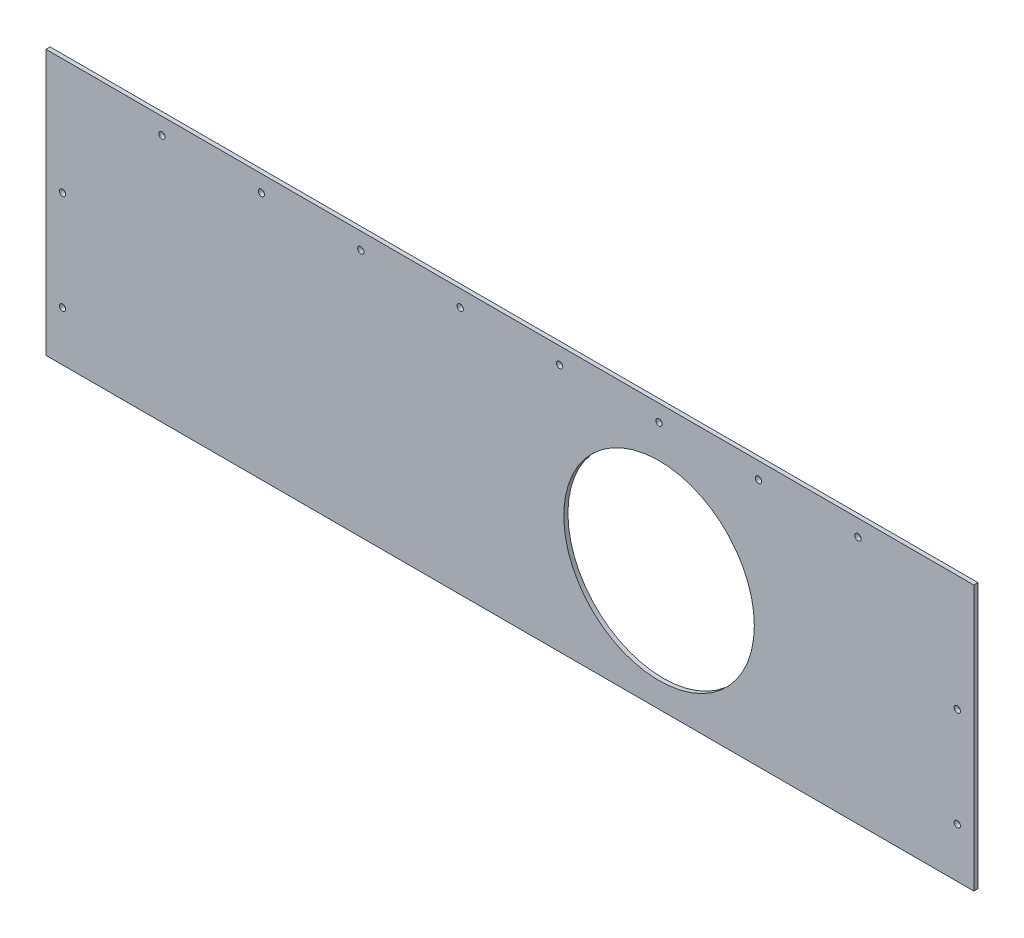
from build123d import *

# Parameters (mm, degrees)
SKETCH1_W           = 711.2
SKETCH1_H           = 203.2
BOSS_EXTRUDE1_DEPTH = 3.175
CUT_EXTRUDE1_REACH  = 5.175
SKETCH2_R           = 2.413
CUT_EXTRUDE2_REACH  = 5.175
SKETCH3_R           = 73.025


with BuildPart() as part:
    # Sketch1 → Boss-Extrude1 (new body)
    with BuildSketch(Plane.XY):
        with Locations((355.6, 101.6)):
            Rectangle(SKETCH1_W, SKETCH1_H)
    extrude(amount=BOSS_EXTRUDE1_DEPTH)

    # Sketch2 → Cut-Extrude1 (cut, up to next)
    with BuildSketch(Plane.XY.offset(3.175), mode=Mode.PRIVATE) as cut_extrude1_sk1:
        with Locations((12.7, 114.3)):
            Circle(SKETCH2_R)
    cut_extrude1_tool1 = extrude(cut_extrude1_sk1.sketch, amount=-CUT_EXTRUDE1_REACH, mode=Mode.PRIVATE) & part.part
    add(cut_extrude1_tool1.solids().sort_by_distance((12.7, 114.3, 3.175))[0], mode=Mode.SUBTRACT)
    # Sketch2 → Cut-Extrude1 (cut, up to next)
    with BuildSketch(Plane.XY.offset(3.175), mode=Mode.PRIVATE) as cut_extrude1_sk2:
        with Locations((698.5, 114.3)):
            Circle(SKETCH2_R)
    cut_extrude1_tool2 = extrude(cut_extrude1_sk2.sketch, amount=-CUT_EXTRUDE1_REACH, mode=Mode.PRIVATE) & part.part
    add(cut_extrude1_tool2.solids().sort_by_distance((698.5, 114.3, 3.175))[0], mode=Mode.SUBTRACT)
    # Sketch2 → Cut-Extrude1 (cut, up to next)
    with BuildSketch(Plane.XY.offset(3.175), mode=Mode.PRIVATE) as cut_extrude1_sk3:
        with Locations((12.7, 38.1)):
            Circle(SKETCH2_R)
    cut_extrude1_tool3 = extrude(cut_extrude1_sk3.sketch, amount=-CUT_EXTRUDE1_REACH, mode=Mode.PRIVATE) & part.part
    add(cut_extrude1_tool3.solids().sort_by_distance((12.7, 38.1, 3.175))[0], mode=Mode.SUBTRACT)
    # Sketch2 → Cut-Extrude1 (cut, up to next)
    with BuildSketch(Plane.XY.offset(3.175), mode=Mode.PRIVATE) as cut_extrude1_sk4:
        with Locations((698.5, 38.1)):
            Circle(SKETCH2_R)
    cut_extrude1_tool4 = extrude(cut_extrude1_sk4.sketch, amount=-CUT_EXTRUDE1_REACH, mode=Mode.PRIVATE) & part.part
    add(cut_extrude1_tool4.solids().sort_by_distance((698.5, 38.1, 3.175))[0], mode=Mode.SUBTRACT)
    # Sketch2 → Cut-Extrude1 (cut, up to next)
    with BuildSketch(Plane.XY.offset(3.175), mode=Mode.PRIVATE) as cut_extrude1_sk5:
        with Locations((88.9, 190.5)):
            Circle(SKETCH2_R)
    cut_extrude1_tool5 = extrude(cut_extrude1_sk5.sketch, amount=-CUT_EXTRUDE1_REACH, mode=Mode.PRIVATE) & part.part
    add(cut_extrude1_tool5.solids().sort_by_distance((88.9, 190.5, 3.175))[0], mode=Mode.SUBTRACT)
    # Sketch2 → Cut-Extrude1 (cut, up to next)
    with BuildSketch(Plane.XY.offset(3.175), mode=Mode.PRIVATE) as cut_extrude1_sk6:
        with Locations((165.1, 190.5)):
            Circle(SKETCH2_R)
    cut_extrude1_tool6 = extrude(cut_extrude1_sk6.sketch, amount=-CUT_EXTRUDE1_REACH, mode=Mode.PRIVATE) & part.part
    add(cut_extrude1_tool6.solids().sort_by_distance((165.1, 190.5, 3.175))[0], mode=Mode.SUBTRACT)
    # Sketch2 → Cut-Extrude1 (cut, up to next)
    with BuildSketch(Plane.XY.offset(3.175), mode=Mode.PRIVATE) as cut_extrude1_sk7:
        with Locations((241.3, 190.5)):
            Circle(SKETCH2_R)
    cut_extrude1_tool7 = extrude(cut_extrude1_sk7.sketch, amount=-CUT_EXTRUDE1_REACH, mode=Mode.PRIVATE) & part.part
    add(cut_extrude1_tool7.solids().sort_by_distance((241.3, 190.5, 3.175))[0], mode=Mode.SUBTRACT)
    # Sketch2 → Cut-Extrude1 (cut, up to next)
    with BuildSketch(Plane.XY.offset(3.175), mode=Mode.PRIVATE) as cut_extrude1_sk8:
        with Locations((622.3, 190.5)):
            Circle(SKETCH2_R)
    cut_extrude1_tool8 = extrude(cut_extrude1_sk8.sketch, amount=-CUT_EXTRUDE1_REACH, mode=Mode.PRIVATE) & part.part
    add(cut_extrude1_tool8.solids().sort_by_distance((622.3, 190.5, 3.175))[0], mode=Mode.SUBTRACT)
    # Sketch2 → Cut-Extrude1 (cut, up to next)
    with BuildSketch(Plane.XY.offset(3.175), mode=Mode.PRIVATE) as cut_extrude1_sk9:
        with Locations((546.1, 190.5)):
            Circle(SKETCH2_R)
    cut_extrude1_tool9 = extrude(cut_extrude1_sk9.sketch, amount=-CUT_EXTRUDE1_REACH, mode=Mode.PRIVATE) & part.part
    add(cut_extrude1_tool9.solids().sort_by_distance((546.1, 190.5, 3.175))[0], mode=Mode.SUBTRACT)
    # Sketch2 → Cut-Extrude1 (cut, up to next)
    with BuildSketch(Plane.XY.offset(3.175), mode=Mode.PRIVATE) as cut_extrude1_sk10:
        with Locations((469.9, 190.5)):
            Circle(SKETCH2_R)
    cut_extrude1_tool10 = extrude(cut_extrude1_sk10.sketch, amount=-CUT_EXTRUDE1_REACH, mode=Mode.PRIVATE) & part.part
    add(cut_extrude1_tool10.solids().sort_by_distance((469.9, 190.5, 3.175))[0], mode=Mode.SUBTRACT)
    # Sketch2 → Cut-Extrude1 (cut, up to next)
    with BuildSketch(Plane.XY.offset(3.175), mode=Mode.PRIVATE) as cut_extrude1_sk11:
        with Locations((393.7, 190.5)):
            Circle(SKETCH2_R)
    cut_extrude1_tool11 = extrude(cut_extrude1_sk11.sketch, amount=-CUT_EXTRUDE1_REACH, mode=Mode.PRIVATE) & part.part
    add(cut_extrude1_tool11.solids().sort_by_distance((393.7, 190.5, 3.175))[0], mode=Mode.SUBTRACT)
    # Sketch2 → Cut-Extrude1 (cut, up to next)
    with BuildSketch(Plane.XY.offset(3.175), mode=Mode.PRIVATE) as cut_extrude1_sk12:
        with Locations((317.5, 190.5)):
            Circle(SKETCH2_R)
    cut_extrude1_tool12 = extrude(cut_extrude1_sk12.sketch, amount=-CUT_EXTRUDE1_REACH, mode=Mode.PRIVATE) & part.part
    add(cut_extrude1_tool12.solids().sort_by_distance((317.5, 190.5, 3.175))[0], mode=Mode.SUBTRACT)

    # Sketch3 → Cut-Extrude2 (cut, up to next)
    with BuildSketch(Plane.XY.offset(3.175), mode=Mode.PRIVATE) as cut_extrude2_sk1:
        with Locations((469.9, 92.075)):
            Circle(SKETCH3_R)
    cut_extrude2_tool1 = extrude(cut_extrude2_sk1.sketch, amount=-CUT_EXTRUDE2_REACH, mode=Mode.PRIVATE) & part.part
    add(cut_extrude2_tool1.solids().sort_by_distance((469.9, 92.075, 3.175))[0], mode=Mode.SUBTRACT)


solid = part.part
